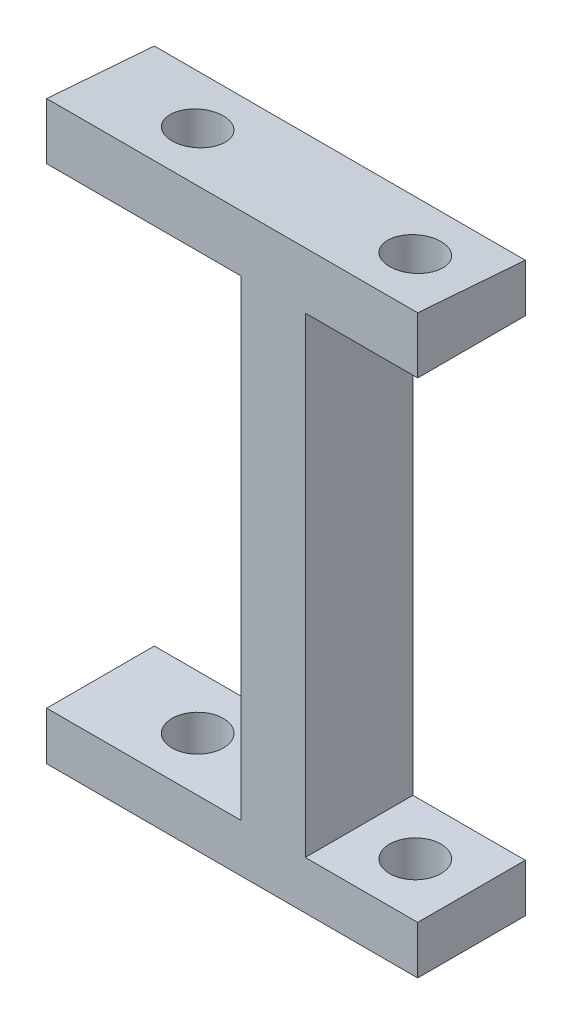
from build123d import *

# Parameters (mm, degrees)
SKETCH2_W                      = 6.7
SKETCH2_H                      = 3
BOSS_EXTRUDE1_DEPTH            = 12.100000416
BOSS_EXTRUDE1_2_DEPTH          = 12.100000416
BOSS_EXTRUDE2_START            = -12.1
SKETCH2_3_W                    = 6.7
SKETCH2_3_H                    = 3
SKETCH2_3_H_2                  = 29.35460187
BOSS_EXTRUDE2_DEPTH            = 4
CUT_EXTRUDE1_REACH             = 78.977
SKETCH3_R                      = 1.6
CUT_EXTRUDE1_DIRECTION_2_DEPTH = 77.976712266
BOSS_EXTRUDE4_START            = -16.100002
SKETCH2_4_W                    = 6.7
SKETCH2_4_H                    = 3
BOSS_EXTRUDE4_DEPTH            = 7
CUT_EXTRUDE2_REACH             = 78.977
SKETCH6_R                      = 1.6
CUT_EXTRUDE2_DIRECTION_2_DEPTH = 77.976712266


with BuildPart() as part:
    # Sketch2 → Boss-Extrude1 (new body)
    with BuildSketch(Plane.ZY.offset(37.766138352)):
        with Locations((55.120130346, -55.592329425)):
            Rectangle(SKETCH2_W, SKETCH2_H)
    extrude(amount=-BOSS_EXTRUDE1_DEPTH)



with BuildPart() as body_2:
    # Sketch2 → Boss-Extrude1 2 (new body)
    with BuildSketch(Plane.ZY.offset(37.766138352)):
        Polygon((51.770130346, -21.737727555), (51.770130346, -24.737727555), (58.470130346, -24.737727555), (58.470130346, -21.223242389), align=None)
    extrude(amount=-BOSS_EXTRUDE1_2_DEPTH)


with BuildPart() as part_1:
    add(part.part)

    add(body_2.part)  # Boss-Extrude2 merges body 2
    # Sketch2_3 → Boss-Extrude2 (add)
    with BuildSketch(Plane.ZY.offset(37.766138352).offset(BOSS_EXTRUDE2_START)):
        with Locations((55.120130346, -55.592329425)):
            Rectangle(SKETCH2_3_W, SKETCH2_3_H)
        with Locations((55.120130346, -39.41502849)):
            Rectangle(SKETCH2_3_W, SKETCH2_3_H_2)
        Polygon((51.770130346, -21.737727555), (51.770130346, -24.737727555), (58.470130346, -24.737727555), (58.470130346, -21.223242389), align=None)
    extrude(amount=-BOSS_EXTRUDE2_DEPTH)

    # Sketch3 → Cut-Extrude1 (cut, up to next)
    with BuildSketch(Plane(origin=(0, -54.092329425, 0), x_dir=(1, 0, 0), z_dir=(0, 1, 0)), mode=Mode.PRIVATE) as cut_extrude1_sk1:
        with Locations(Location((-31.716139041, -55.120130346, 0), (0, 0, 180))):
            Circle(SKETCH3_R)
    cut_extrude1_tool1 = extrude(cut_extrude1_sk1.sketch, amount=-CUT_EXTRUDE1_REACH, mode=Mode.PRIVATE) & part_1.part
    add(cut_extrude1_tool1.solids().sort_by_distance((-31.716139, -54.092329, 55.12013))[0], mode=Mode.SUBTRACT)

    # Sketch3 → Cut-Extrude1 direction 2 (cut)
    with BuildSketch(Plane(origin=(0, -54.092329425, 0), x_dir=(1, 0, 0), z_dir=(0, 1, 0))):
        with Locations(Location((-31.716139041, -55.120130346, 0), (0, 0, 180))):
            Circle(SKETCH3_R)
    extrude(amount=CUT_EXTRUDE1_DIRECTION_2_DEPTH, mode=Mode.SUBTRACT)


with BuildPart() as boss_extrude4_tool:
    # Sketch2_4 → Boss-Extrude4 (new body)
    with BuildSketch(Plane.ZY.offset(37.766138352).offset(BOSS_EXTRUDE4_START)):
        with Locations((55.120130346, -55.592329425)):
            Rectangle(SKETCH2_4_W, SKETCH2_4_H)
        Polygon((51.770130346, -21.737727555), (51.770130346, -24.737727555), (58.470130346, -24.737727555), (58.470130346, -21.223242389), align=None)
    extrude(amount=-BOSS_EXTRUDE4_DEPTH)


with BuildPart() as part_2:
    add(part_1.part)


with BuildPart() as part_3:
    # Boss-Extrude4: joined with boss_extrude4_tool
    add(part_2.part.fuse(boss_extrude4_tool.part, tol=0.00001))

    # Sketch6 → Cut-Extrude2 (cut, up to next)
    with BuildSketch(Plane(origin=(0, -54.092329425, 0), x_dir=(1, 0, 0), z_dir=(0, 1, 0)), mode=Mode.PRIVATE) as cut_extrude2_sk1:
        with Locations(Location((-18.166139731, -55.120130346, 0), (0, 0, 90))):
            Circle(SKETCH6_R)
    cut_extrude2_tool1 = extrude(cut_extrude2_sk1.sketch, amount=-CUT_EXTRUDE2_REACH, mode=Mode.PRIVATE) & part_3.part
    add(cut_extrude2_tool1.solids().sort_by_distance((-18.16614, -54.092329, 55.12013))[0], mode=Mode.SUBTRACT)

    # Sketch6 → Cut-Extrude2 direction 2 (cut)
    with BuildSketch(Plane(origin=(0, -54.092329425, 0), x_dir=(1, 0, 0), z_dir=(0, 1, 0))):
        with Locations(Location((-18.166139731, -55.120130346, 0), (0, 0, 90))):
            Circle(SKETCH6_R)
    extrude(amount=CUT_EXTRUDE2_DIRECTION_2_DEPTH, mode=Mode.SUBTRACT)


solid = part_3.part
